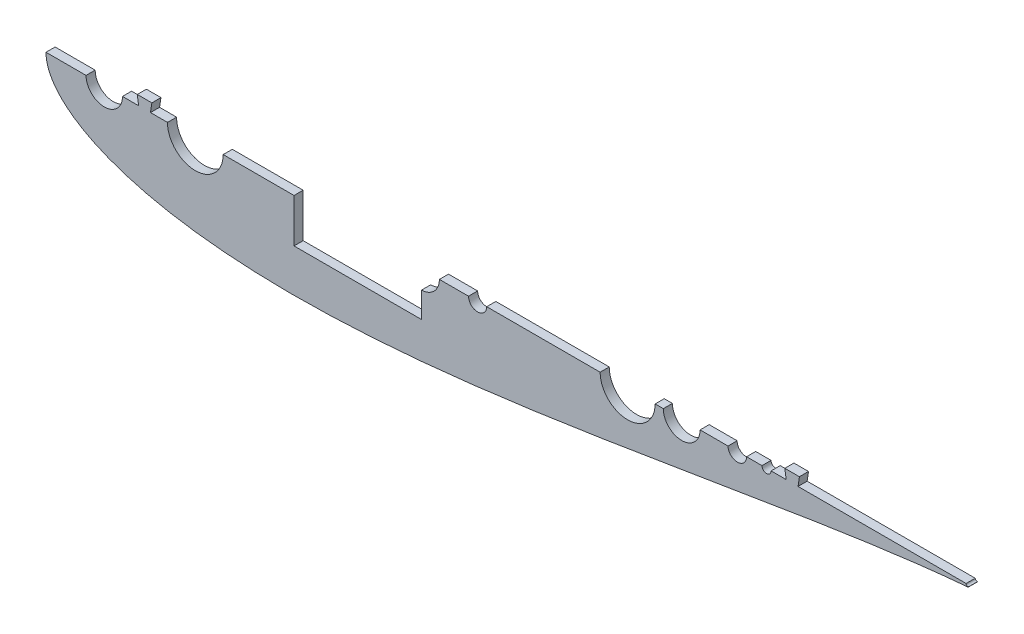
from build123d import *

# Parameters (mm, degrees)
BOSS_EXTRUDE1_DEPTH     = 6.35
CUT_EXTRUDE2_DEPTH      = 1.0000001
CUT_EXTRUDE2_DEPTH_BACK = 7.3500001
SKETCH4_W               = 6.35
SKETCH4_H               = 6.35
BOSS_EXTRUDE2_DEPTH     = 6.35
SKETCH7_W               = 88.9
SKETCH7_H               = 60.96
CUT_EXTRUDE4_DEPTH      = 7.3500001
SKETCH8_R               = 1.2446
CUT_EXTRUDE5_DEPTH      = 7.3500001


with BuildPart() as part:
    # Sketch2 → Boss-Extrude1 (new body)
    with BuildSketch(Plane.XY):
        with BuildLine():
            Line((460.660965279, 0), (123.571, 0))
            ThreePointArc((123.571, 0), (104.14, -19.431), (84.709, 0))
            Line((84.709, 0), (53.34, 0))
            ThreePointArc((53.34, 0), (40.64, -12.7), (27.94, 0))
            Line((27.94, 0), (0, 0))
            add(Edge.make_bspline(
                [(0, 0), (0, -1.007496172), (0.154611582, -3.513796615), (1.106333228, -7.923389435), (3.463136343, -13.420354421), (7.689616489, -19.513207632), (13.932423524, -25.726412106), (22.129107375, -31.731455339), (32.141645239, -37.332204029), (43.82045433, -42.41500246), (57.023709725, -46.912543066), (71.619696083, -50.784752003), (87.485018636, -54.008935199), (104.502313427, -56.574303932), (122.558104573, -58.481758104), (141.542033828, -59.739895824), (161.345829027, -60.366961324), (181.863132616, -60.387506142), (202.989192599, -59.8341217), (224.620860897, -58.745176641), (246.65655865, -57.164603829), (268.996310773, -55.141201012), (291.541767704, -52.727712704), (314.196207315, -49.979843895), (336.86454415, -46.955447457), (359.453314895, -43.713502532), (381.870662856, -40.313266856), (404.02631566, -36.813220545), (425.831595832, -33.270324121), (447.199424328, -29.739007432), (468.044367735, -26.27043606), (488.282710288, -22.911672601), (507.832591566, -19.705111663), (526.614143658, -16.687720753), (544.549749946, -13.890665375), (561.564270734, -11.338919625), (577.585454095, -9.050636147), (592.543922516, -7.037634907), (606.374988512, -5.304428983), (619.014124193, -3.849253664), (630.413817462, -2.663385493), (638.093728429, -1.953546407), (641.993392355, -1.625070631), (642.510849283, -1.582039112)],
                knots=[0.5, 0.5, 0.5, 0.5, 0.502166769, 0.505390167, 0.509655974, 0.514947682, 0.521244711, 0.528520886, 0.536744945, 0.54588136, 0.555890751, 0.566730119, 0.57835299, 0.590709588, 0.603747039, 0.617409572, 0.631638768, 0.646373793, 0.661551658, 0.677107483, 0.692974771, 0.709085713, 0.725371443, 0.741762353, 0.758188398, 0.774579367, 0.790865214, 0.806976332, 0.822843867, 0.838400002, 0.853578262, 0.868313774, 0.882543568, 0.896206835, 0.909245173, 0.92160287, 0.933227116, 0.944068236, 0.954079898, 0.963219316, 0.971447445, 0.978729112, 0.979842958, 0.979842958, 0.979842958, 0.979842958], degree=3))
            ThreePointArc((642.510849283, -1.582039112), (643.547407924, -1.075012082), (643.966787522, 0))
            Line((643.966787522, 0), (473.360965279, 0))
            Line((473.360965279, 0), (460.660965279, 0))
        make_face()
    extrude(amount=BOSS_EXTRUDE1_DEPTH)

    # Sketch3 → Cut-Extrude2 (cut, two sides)
    with BuildSketch(Plane.XY.offset(6.35)) as cut_extrude2_sk:
        with BuildLine():
            ThreePointArc((424.77879385, 0), (405.60179385, 19.177), (386.42479385, 0))
            Line((386.42479385, 0), (424.77879385, 0))
        make_face()
        with BuildLine():
            Line((424.77879385, 0), (386.42479385, 0))
            ThreePointArc((386.42479385, 0), (405.60179385, -19.177), (424.77879385, 0))
        make_face()
        with BuildLine():
            ThreePointArc((430.474866123, 0), (443.301866123, -12.827), (456.128866123, 0))
            Line((456.128866123, 0), (430.474866123, 0))
        make_face()
        with BuildLine():
            Line((430.474866123, 0), (456.128866123, 0))
            ThreePointArc((456.128866123, 0), (443.301866123, 12.827), (430.474866123, 0))
        make_face()
        with BuildLine():
            ThreePointArc((475.605534569, 0), (482.082534569, -6.477), (488.559534569, 0))
            Line((488.559534569, 0), (475.605534569, 0))
        make_face()
        with BuildLine():
            Line((475.605534569, 0), (488.559534569, 0))
            ThreePointArc((488.559534569, 0), (482.082534569, 6.477), (475.605534569, 0))
        make_face()
        with BuildLine():
            ThreePointArc((499.299992417, 0), (502.474992417, -3.175), (505.649992417, 0))
            Line((505.649992417, 0), (499.299992417, 0))
        make_face()
        with BuildLine():
            Line((499.299992417, 0), (505.649992417, 0))
            ThreePointArc((505.649992417, 0), (502.474992417, 3.175), (499.299992417, 0))
        make_face()
        with BuildLine():
            ThreePointArc((274.32, 0), (261.62, 12.7), (248.92, 0))
            Line((248.92, 0), (274.32, 0))
        make_face()
        with BuildLine():
            Line((274.32, 0), (248.92, 0))
            ThreePointArc((248.92, 0), (261.62, -12.7), (274.32, 0))
        make_face()
        with BuildLine():
            ThreePointArc((294.64, 0), (300.99, -6.35), (307.34, 0))
            Line((307.34, 0), (294.64, 0))
        make_face()
        with BuildLine():
            Line((294.64, 0), (307.34, 0))
            ThreePointArc((307.34, 0), (300.99, 6.35), (294.64, 0))
        make_face()
    extrude(amount=CUT_EXTRUDE2_DEPTH, mode=Mode.SUBTRACT)
    extrude(cut_extrude2_sk.sketch, amount=-CUT_EXTRUDE2_DEPTH_BACK, mode=Mode.SUBTRACT)

    # Sketch4 → Boss-Extrude2 (add)
    with BuildSketch(Plane.XY.offset(6.35)):
        Polygon((516.182034569, 0), (517.134534569, 0), (517.134534569, 6.35), (515.229534569, 6.35), align=None)
        with Locations((520.309534569, 3.175)):
            Rectangle(SKETCH4_W, SKETCH4_H)
        Polygon((523.484534569, 0), (524.437034569, 0), (525.389534569, 6.35), (523.484534569, 6.35), align=None)
        Polygon((65.565, 6.35), (63.66, 6.35), (64.6125, 0), (65.565, 0), align=None)
        with Locations((68.74, 3.175)):
            Rectangle(SKETCH4_W, SKETCH4_H)
        Polygon((73.82, 6.35), (71.915, 6.35), (71.915, 0), (72.8675, 0), align=None)
    extrude(amount=-BOSS_EXTRUDE2_DEPTH)

    # Sketch7 → Cut-Extrude4 (cut, through all)
    with BuildSketch(Plane(origin=(327.95923074, -13.751410445, 6.35), x_dir=(1, 0, 0), z_dir=(0, 0, 1))):
        with Locations((-110.53523074, 13.751410445)):
            Rectangle(SKETCH7_W, SKETCH7_H)
    extrude(amount=-CUT_EXTRUDE4_DEPTH, mode=Mode.SUBTRACT)

    # Sketch8 → Cut-Extrude5 (cut, through all)
    with BuildSketch(Plane(origin=(327.95923074, -13.751410445, 6.35), x_dir=(1, 0, 0), z_dir=(0, 0, 1))):
        with Locations((314.928477568, 13.751410445)):
            Circle(SKETCH8_R)
    extrude(amount=-CUT_EXTRUDE5_DEPTH, mode=Mode.SUBTRACT)


solid = part.part
